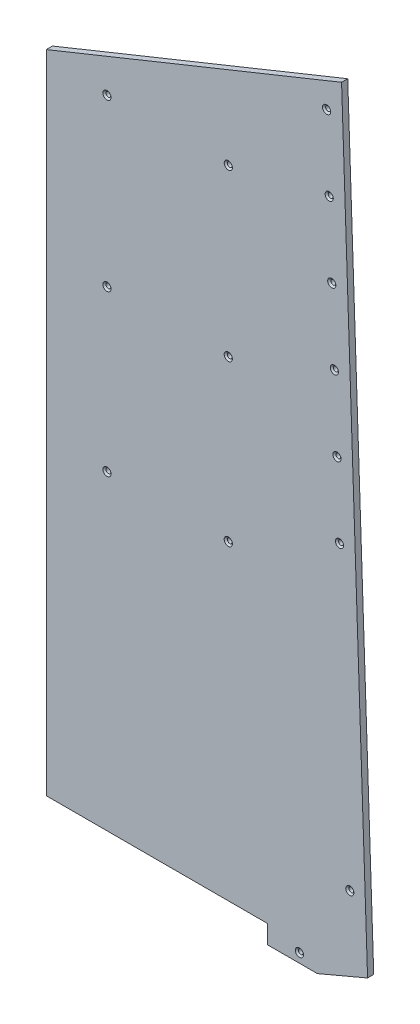
from build123d import *

# Parameters (mm, degrees)
BOSS_EXTRUDE1_DEPTH                               = 6.35
BOSS_EXTRUDE2_DEPTH                               = 6.35
CSK_FOR_8_FLAT_HEAD_MACHINE_SCREW_100_D           = 4.9149
CSK_FOR_8_FLAT_HEAD_MACHINE_SCREW_100_DEPTH       = 6.35
CSK_FOR_8_FLAT_HEAD_MACHINE_SCREW_100_CSINK_D     = 8.4328
CSK_FOR_8_FLAT_HEAD_MACHINE_SCREW_100_CSINK_ANGLE = 100


with BuildPart() as part:
    # Sketch1 → Boss-Extrude1 (new body)
    with BuildSketch(Plane.XY):
        Polygon((2683.510000011, 6621.1958), (2683.510000013, 5955.03), (2911.730002065, 5955.03), (2911.730002065, 5935.980000183), (2962.998658572, 5935.980000183), (3014.728804207, 5957.938144244), (2987.930002065, 6744.189464503), align=None)
    extrude(amount=BOSS_EXTRUDE1_DEPTH)

    # Sketch2 → Boss-Extrude2 (add)
    with BuildSketch(Plane.XY.offset(6.35)):
        Polygon((2933.697739453, 6621.1958), (2683.510000011, 6621.1958), (2683.510000386, 6602.1458), (2933.697739453, 6602.1458), align=None)
    extrude(amount=-BOSS_EXTRUDE2_DEPTH)

    # CSK for #8 Flat Head Machine Screw (100)2
    with Locations(Plane.XY.offset(6.35)):
        with Locations((2871.150804655, 6611.6708), (2746.056935059, 6611.6708), (2746.056934863, 6440.805), (2871.15080459, 6440.805), (2746.0569351, 6275.705000214), (2871.150804763, 6275.705000214), (2944.446214291, 5945.505000556), (2996.439588076, 6026.795207351), (2985.802221481, 6331.409531427), (2983.142879832, 6407.563112446), (2980.483538184, 6483.716693465), (2977.824196535, 6559.870274483), (2975.164854886, 6636.023855502), (2972.505513237, 6712.177436521)):
            CounterSinkHole(CSK_FOR_8_FLAT_HEAD_MACHINE_SCREW_100_D / 2, CSK_FOR_8_FLAT_HEAD_MACHINE_SCREW_100_CSINK_D / 2, depth=CSK_FOR_8_FLAT_HEAD_MACHINE_SCREW_100_DEPTH, counter_sink_angle=CSK_FOR_8_FLAT_HEAD_MACHINE_SCREW_100_CSINK_ANGLE)


solid = part.part
